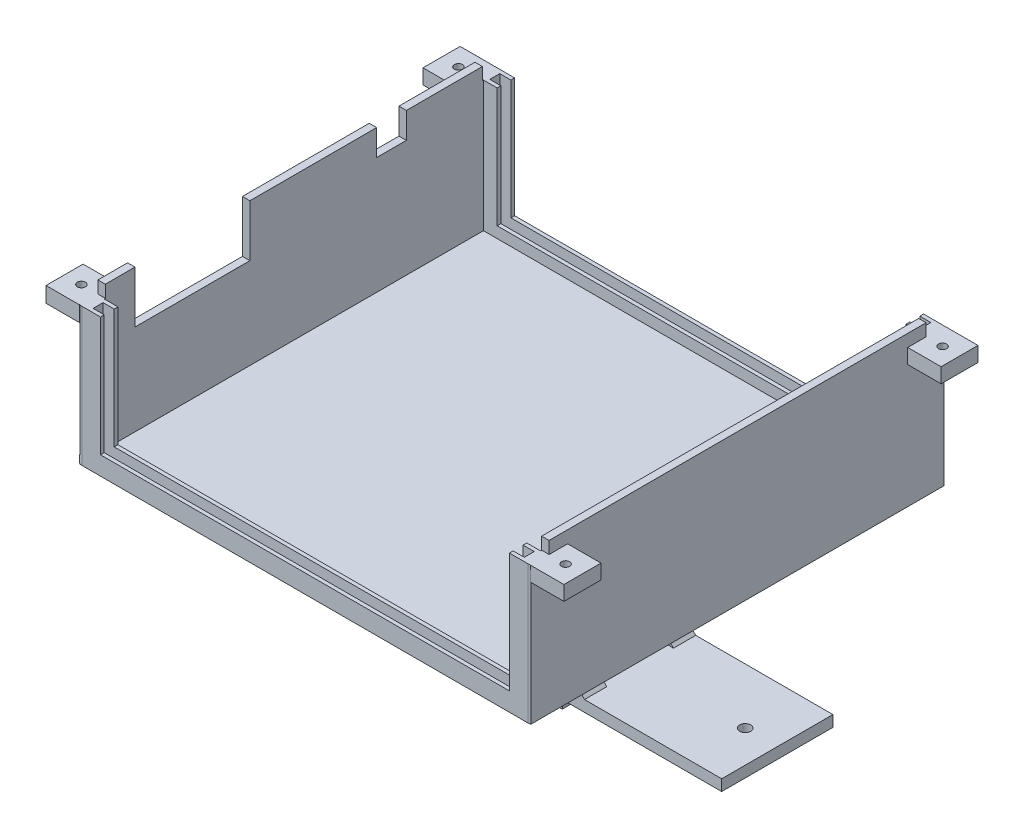
from build123d import *

# Parameters (mm, degrees)
SKETCH1_W            = 124.4
SKETCH1_H            = 111.7
BOSS_EXTRUDE1_DEPTH  = 2
SKETCH2_W            = 2
SKETCH2_H            = 101.7
BOSS_EXTRUDE2_DEPTH  = 38.5
SKETCH3_W            = 121.7
SKETCH3_H            = 4.7
BOSS_EXTRUDE3_DEPTH  = 3
SKETCH5_W            = 116.3
SKETCH5_H            = 2.7
CUT_EXTRUDE8_DEPTH   = 3
SKETCH14_W           = 121.7
SKETCH14_H           = 4.7
BOSS_EXTRUDE6_DEPTH  = 3
SKETCH15_W           = 116.3
SKETCH15_H           = 2.7
CUT_EXTRUDE14_DEPTH  = 3
SKETCH18_W           = 2
SKETCH18_H           = 0.3
BOSS_EXTRUDE7_DEPTH  = 35.2
SKETCH19_W           = 5.7
SKETCH19_H           = 4.7
BOSS_EXTRUDE8_DEPTH  = 32.2
SKETCH20_W           = 2.7
SKETCH20_H           = 32.2
CUT_EXTRUDE15_DEPTH  = 3
SKETCH21_W           = 2.7
SKETCH21_H           = 32.2
CUT_EXTRUDE16_DEPTH  = 3
SKETCH24_W           = 2.7
SKETCH24_H           = 32.2
CUT_EXTRUDE18_DEPTH  = 3
SKETCH25_W           = 2.7
SKETCH25_H           = 32.2
CUT_EXTRUDE19_DEPTH  = 3
SKETCH30_W           = 31
SKETCH30_H           = 14
SKETCH30_W_2         = 8
SKETCH30_H_2         = 7
CUT_EXTRUDE23_DEPTH  = 2
SKETCH31_W           = 6
SKETCH31_H           = 36.2
BOSS_EXTRUDE9_DEPTH  = 1.35
FILLET1_R            = 2
SKETCH33_W           = 99.7
SKETCH33_H           = 3
BOSS_EXTRUDE11_DEPTH = 1.35
SKETCH43_W           = 1.229805297
SKETCH43_H           = 112.077966817
CUT_EXTRUDE25_DEPTH  = 38.2
SKETCH47_W           = 57.12
SKETCH47_H           = 30
BOSS_EXTRUDE22_DEPTH = 38
SKETCH49_W           = 51.12
SKETCH49_H           = 30
CUT_EXTRUDE30_DEPTH  = 38
SKETCH51_W           = 2.352063359
SKETCH51_H           = 112.382279656
CUT_EXTRUDE33_DEPTH  = 77.2
SKETCH54_W           = 10
SKETCH54_H           = 4.16571725
SKETCH54_H_2         = 4.016594053
BOSS_EXTRUDE23_DEPTH = 9
SKETCH55_W           = 10
SKETCH55_H           = 3.950767522
SKETCH55_W_2         = 9.95127899
SKETCH55_H_2         = 4
BOSS_EXTRUDE24_DEPTH = 9
SKETCH56_R           = 1.1
CUT_EXTRUDE34_DEPTH  = 10
SKETCH57_R           = 1
CUT_EXTRUDE35_DEPTH  = 99.41
SKETCH58_W           = 30
SKETCH58_H           = 3
BOSS_EXTRUDE25_DEPTH = 43
SKETCH59_W           = 30
SKETCH59_H           = 3.021561104
BOSS_EXTRUDE26_DEPTH = 43
BOSS_EXTRUDE28_DEPTH = 6
BOSS_EXTRUDE29_DEPTH = 6
BOSS_EXTRUDE30_DEPTH = 6
BOSS_EXTRUDE31_DEPTH = 6
SKETCH64_W           = 30
SKETCH64_H           = 6.546083461
CUT_EXTRUDE36_DEPTH  = 101.12
SKETCH65_R           = 1.5
CUT_EXTRUDE37_DEPTH  = 6
SKETCH67_R           = 1.5
CUT_EXTRUDE39_DEPTH  = 6


with BuildPart() as part:
    # Sketch1 → Boss-Extrude1 (new body)
    with BuildSketch(Plane(origin=(0, 0, 0), x_dir=(1, 0, 0), z_dir=(0, 1, 0))):
        with Locations((62.2, 55.85)):
            Rectangle(SKETCH1_W, SKETCH1_H)
    extrude(amount=BOSS_EXTRUDE1_DEPTH)

    # Sketch2 → Boss-Extrude2 (add)
    with BuildSketch(Plane(origin=(0, 2, 0), x_dir=(1, 0, 0), z_dir=(0, 1, 0))):
        with Locations((122.05, 55.85)):
            Rectangle(SKETCH2_W, SKETCH2_H)
        with Locations((2.35, 55.85)):
            Rectangle(SKETCH2_W, SKETCH2_H)
    extrude(amount=BOSS_EXTRUDE2_DEPTH)

    # Sketch3 → Boss-Extrude3 (add)
    with BuildSketch(Plane(origin=(0, 2, 0), x_dir=(1, 0, 0), z_dir=(0, 1, 0))):
        with Locations((62.2, 2.35)):
            Rectangle(SKETCH3_W, SKETCH3_H)
    extrude(amount=BOSS_EXTRUDE3_DEPTH)

    # Sketch5 → Cut-Extrude8 (cut)
    with BuildSketch(Plane(origin=(0, 5, 0), x_dir=(1, 0, 0), z_dir=(0, 1, 0))):
        with Locations((62.2, 2.35)):
            Rectangle(SKETCH5_W, SKETCH5_H)
    extrude(amount=-CUT_EXTRUDE8_DEPTH, mode=Mode.SUBTRACT)

    # Sketch14 → Boss-Extrude6 (add)
    with BuildSketch(Plane(origin=(0, 2, 0), x_dir=(1, 0, 0), z_dir=(0, 1, 0))):
        with Locations((62.2, 109.35)):
            Rectangle(SKETCH14_W, SKETCH14_H)
    extrude(amount=BOSS_EXTRUDE6_DEPTH)

    # Sketch15 → Cut-Extrude14 (cut)
    with BuildSketch(Plane(origin=(0, 5, 0), x_dir=(1, 0, 0), z_dir=(0, 1, 0))):
        with Locations((62.2, 109.35)):
            Rectangle(SKETCH15_W, SKETCH15_H)
    extrude(amount=-CUT_EXTRUDE14_DEPTH, mode=Mode.SUBTRACT)

    # Sketch18 → Boss-Extrude7 (add)
    with BuildSketch(Plane(origin=(0, 2, 0), x_dir=(1, 0, 0), z_dir=(0, 1, 0))):
        with Locations((2.35, 106.85)):
            Rectangle(SKETCH18_W, SKETCH18_H)
        with Locations((122.05, 106.85)):
            Rectangle(SKETCH18_W, SKETCH18_H)
        with Locations((122.05, 4.85)):
            Rectangle(SKETCH18_W, SKETCH18_H)
        with Locations((2.35, 4.85)):
            Rectangle(SKETCH18_W, SKETCH18_H)
    extrude(amount=BOSS_EXTRUDE7_DEPTH)

    # Sketch19 → Boss-Extrude8 (add)
    with BuildSketch(Plane(origin=(0, 5, 0), x_dir=(1, 0, 0), z_dir=(0, 1, 0))):
        with Locations((120.2, 2.35)):
            Rectangle(SKETCH19_W, SKETCH19_H)
        with Locations((4.2, 2.35)):
            Rectangle(SKETCH19_W, SKETCH19_H)
        with Locations((120.2, 109.35)):
            Rectangle(SKETCH19_W, SKETCH19_H)
        with Locations((4.2, 109.35)):
            Rectangle(SKETCH19_W, SKETCH19_H)
    extrude(amount=BOSS_EXTRUDE8_DEPTH)

    # Sketch20 → Cut-Extrude15 (cut)
    with BuildSketch(Plane.ZY.offset(-117.35)):
        with Locations((-109.35, 21.1)):
            Rectangle(SKETCH20_W, SKETCH20_H)
    extrude(amount=-CUT_EXTRUDE15_DEPTH, mode=Mode.SUBTRACT)

    # Sketch21 → Cut-Extrude16 (cut)
    with BuildSketch(Plane(origin=(7.05, 0, 0), x_dir=(0, 0, -1), z_dir=(1, 0, 0))):
        with Locations((109.35, 21.1)):
            Rectangle(SKETCH21_W, SKETCH21_H)
    extrude(amount=-CUT_EXTRUDE16_DEPTH, mode=Mode.SUBTRACT)

    # Sketch24 → Cut-Extrude18 (cut)
    with BuildSketch(Plane(origin=(7.05, 0, 0), x_dir=(0, 0, -1), z_dir=(1, 0, 0))):
        with Locations((2.35, 21.1)):
            Rectangle(SKETCH24_W, SKETCH24_H)
    extrude(amount=-CUT_EXTRUDE18_DEPTH, mode=Mode.SUBTRACT)

    # Sketch25 → Cut-Extrude19 (cut)
    with BuildSketch(Plane.ZY.offset(-117.35)):
        with Locations((-2.35, 21.1)):
            Rectangle(SKETCH25_W, SKETCH25_H)
    extrude(amount=-CUT_EXTRUDE19_DEPTH, mode=Mode.SUBTRACT)

    # Sketch30 → Cut-Extrude23 (cut)
    with BuildSketch(Plane.ZY.offset(-1.35)):
        with Locations((-28.5, 33.5)):
            Rectangle(SKETCH30_W, SKETCH30_H)
        with Locations((-82.2, 37)):
            Rectangle(SKETCH30_W_2, SKETCH30_H_2)
    extrude(amount=-CUT_EXTRUDE23_DEPTH, mode=Mode.SUBTRACT)

    # Sketch31 → Boss-Extrude9 (add)
    with BuildSketch(Plane(origin=(123.05, 0, 0), x_dir=(0, 0, -1), z_dir=(1, 0, 0))):
        with Locations((3, 20.1)):
            Rectangle(SKETCH31_W, SKETCH31_H)
        with Locations((108.7, 20.1)):
            Rectangle(SKETCH31_W, SKETCH31_H)
    extrude(amount=BOSS_EXTRUDE9_DEPTH)

    # Fillet1
    fillet1_edges = [part.edges().sort_by_distance(p)[0] for p in [
        (0, 1, 0),
        (124.4, 19.1, 0),
        (124.4, 19.1, -111.7),
        (0, 1, -111.7),
    ]]
    fillet(fillet1_edges, radius=FILLET1_R)

    # Sketch33 → Boss-Extrude11 (add)
    with BuildSketch(Plane(origin=(123.05, 0, 0), x_dir=(0, 0, -1), z_dir=(1, 0, 0))):
        with Locations((55.85, 3.5)):
            Rectangle(SKETCH33_W, SKETCH33_H)
    extrude(amount=BOSS_EXTRUDE11_DEPTH)

    # Sketch43 → Cut-Extrude25 (cut, through all)
    with BuildSketch(Plane(origin=(0, 37.2, 0), x_dir=(1, 0, 0), z_dir=(0, 1, 0))):
        with Locations((0.614902649, 56.193231497)):
            Rectangle(SKETCH43_W, SKETCH43_H)
    extrude(amount=-CUT_EXTRUDE25_DEPTH, mode=Mode.SUBTRACT)

    # Sketch47 → Boss-Extrude22 (add)
    with BuildSketch(Plane(origin=(0, 0, 0), x_dir=(-1, 0, 0), z_dir=(0, -1, 0))):
        with Locations((-62.2, 55.85)):
            Rectangle(SKETCH47_W, SKETCH47_H)
    extrude(amount=BOSS_EXTRUDE22_DEPTH)

    # Sketch49 → Cut-Extrude30 (cut)
    with BuildSketch(Plane(origin=(0, -38, 0), x_dir=(-1, 0, 0), z_dir=(0, -1, 0))):
        with Locations((-62.2, 55.85)):
            Rectangle(SKETCH49_W, SKETCH49_H)
    extrude(amount=-CUT_EXTRUDE30_DEPTH, mode=Mode.SUBTRACT)

    # Sketch51 → Cut-Extrude33 (cut, through all)
    with BuildSketch(Plane(origin=(0, 38.2, 0), x_dir=(1, 0, 0), z_dir=(0, 1, 0))):
        with Locations((124.22603168, 56.299711796)):
            Rectangle(SKETCH51_W, SKETCH51_H)
    extrude(amount=-CUT_EXTRUDE33_DEPTH, mode=Mode.SUBTRACT)

    # Sketch54 → Boss-Extrude23 (add)
    with BuildSketch(Plane.ZY.offset(-1.35)):
        with Locations((-5, 35.117141375)):
            Rectangle(SKETCH54_W, SKETCH54_H)
        with Locations((-106.7, 35.191702973)):
            Rectangle(SKETCH54_W, SKETCH54_H_2)
    extrude(amount=BOSS_EXTRUDE23_DEPTH)

    # Sketch55 → Boss-Extrude24 (add)
    with BuildSketch(Plane(origin=(123.05, 0, 0), x_dir=(0, 0, -1), z_dir=(1, 0, 0))):
        with Locations((5, 35.224616239)):
            Rectangle(SKETCH55_W, SKETCH55_H)
        with Locations((106.724360505, 35.2)):
            Rectangle(SKETCH55_W_2, SKETCH55_H_2)
    extrude(amount=BOSS_EXTRUDE24_DEPTH)

    # Sketch56 → Cut-Extrude34 (cut)
    with BuildSketch(Plane(origin=(0, 37.2, 0), x_dir=(1, 0, 0), z_dir=(0, 1, 0))):
        with Locations((-3.1, 106.7)):
            Circle(SKETCH56_R)
        with Locations((127.5, 106.7)):
            Circle(SKETCH56_R)
        with Locations((127.5, 5)):
            Circle(SKETCH56_R)
        with Locations((-3.1, 5)):
            Circle(SKETCH56_R)
    extrude(amount=-CUT_EXTRUDE34_DEPTH, mode=Mode.SUBTRACT)

    # Sketch57 → Cut-Extrude35 (cut, through all)
    with BuildSketch(Plane(origin=(90.76, 0, 0), x_dir=(0, 0, -1), z_dir=(1, 0, 0))):
        with Locations((45.85, -34)):
            Circle(SKETCH57_R)
        with Locations((65.85, -34)):
            Circle(SKETCH57_R)
    extrude(amount=-CUT_EXTRUDE35_DEPTH, mode=Mode.SUBTRACT)

    # Sketch58 → Boss-Extrude25 (add)
    with BuildSketch(Plane(origin=(90.76, 0, 0), x_dir=(0, 0, -1), z_dir=(1, 0, 0))):
        with Locations((55.85, -29.25)):
            Rectangle(SKETCH58_W, SKETCH58_H)
    extrude(amount=BOSS_EXTRUDE25_DEPTH)

    # Sketch59 → Boss-Extrude26 (add)
    with BuildSketch(Plane.ZY.offset(-33.64)):
        with Locations((-55.85, -29.239219448)):
            Rectangle(SKETCH59_W, SKETCH59_H)
    extrude(amount=BOSS_EXTRUDE26_DEPTH)

    # Sketch61 → Boss-Extrude28 (add)
    with BuildSketch(Plane.XY.offset(-40.85)):
        Polygon((90.76, -21.75), (96.76, -27.75), (90.76, -27.75), align=None)
    extrude(amount=-BOSS_EXTRUDE28_DEPTH)

    # Sketch62 → Boss-Extrude29 (add)
    with BuildSketch(Plane(origin=(0, 0, -70.85), x_dir=(-1, 0, 0), z_dir=(0, 0, -1))):
        Polygon((-90.76, -21.75), (-90.76, -27.75), (-96.76, -27.75), align=None)
    extrude(amount=-BOSS_EXTRUDE29_DEPTH)

    # Sketch60 → Boss-Extrude30 (add)
    with BuildSketch(Plane.XY.offset(-40.85)):
        Polygon((27.64, -27.728438896), (33.64, -21.728438896), (33.64, -27.728438896), align=None)
    extrude(amount=-BOSS_EXTRUDE30_DEPTH)

    # Sketch63 → Boss-Extrude31 (add)
    with BuildSketch(Plane(origin=(0, 0, -70.85), x_dir=(-1, 0, 0), z_dir=(0, 0, -1))):
        Polygon((-33.64, -22.069435851), (-33.64, -27.728438896), (-27.64, -27.728438896), align=None)
    extrude(amount=-BOSS_EXTRUDE31_DEPTH)

    # Sketch64 → Cut-Extrude36 (cut, through all)
    with BuildSketch(Plane.ZY.offset(-33.64)):
        with Locations((-55.85, -36.27304173)):
            Rectangle(SKETCH64_W, SKETCH64_H)
    extrude(amount=-CUT_EXTRUDE36_DEPTH, mode=Mode.SUBTRACT)

    # Sketch65 → Cut-Extrude37 (cut)
    with BuildSketch(Plane(origin=(0, -30.75, 0), x_dir=(-1, 0, 0), z_dir=(0, -1, 0))):
        with Locations((-125.11, 55.85)):
            Circle(SKETCH65_R)
    extrude(amount=-CUT_EXTRUDE37_DEPTH, mode=Mode.SUBTRACT)

    # Sketch67 → Cut-Extrude39 (cut)
    with BuildSketch(Plane.XZ.offset(30.75)):
        with Locations((-0.71, -55.85)):
            Circle(SKETCH67_R)
    extrude(amount=-CUT_EXTRUDE39_DEPTH, mode=Mode.SUBTRACT)


solid = part.part
